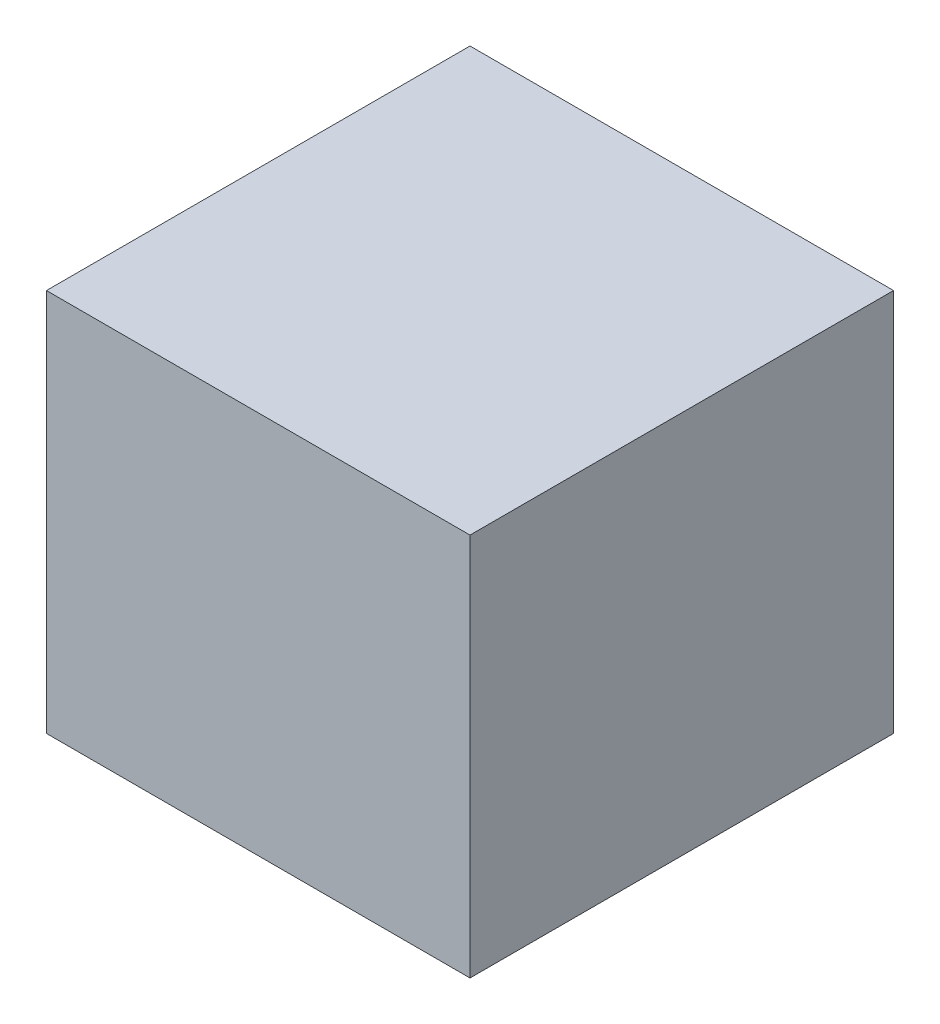
from build123d import *

# Parameters (mm, degrees)
SKETCH1_W           = 31.8
SKETCH1_H           = 31.8
BOSS_EXTRUDE1_DEPTH = 28.8


with BuildPart() as part:
    # Sketch1 → Boss-Extrude1 (new body)
    with BuildSketch(Plane(origin=(0, 0, 0), x_dir=(1, 0, 0), z_dir=(0, 1, 0))):
        Rectangle(SKETCH1_W, SKETCH1_H)
    extrude(amount=BOSS_EXTRUDE1_DEPTH)


solid = part.part
